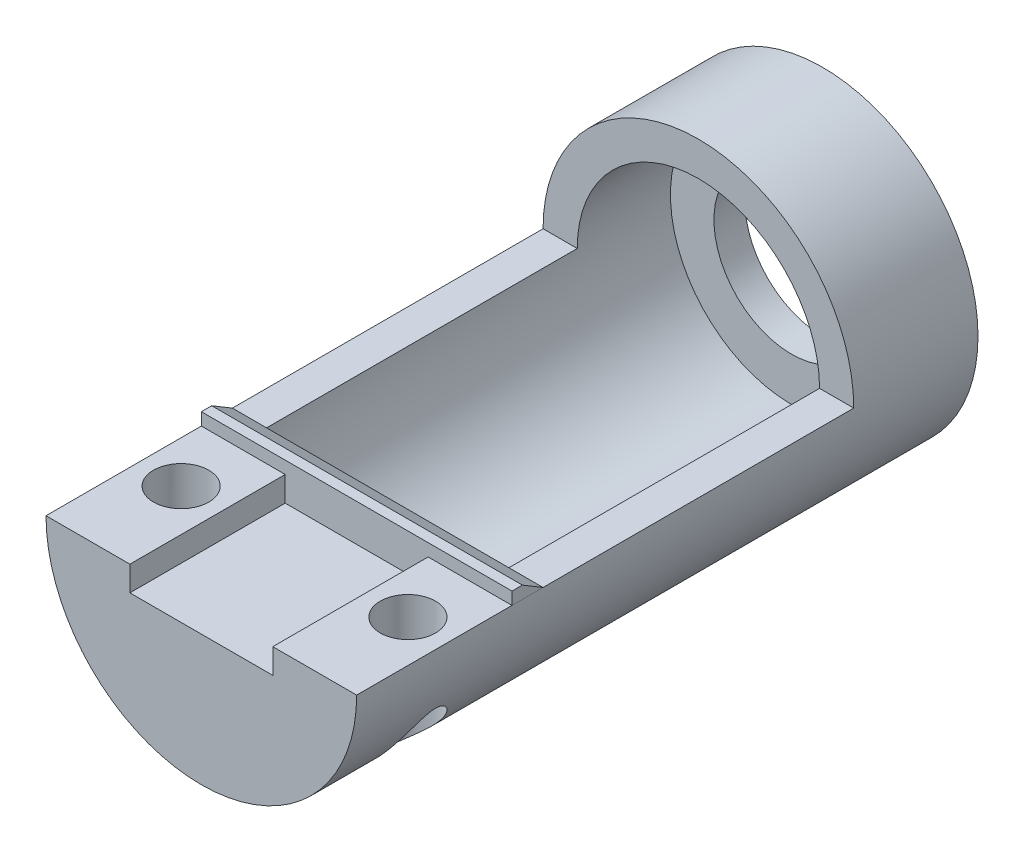
from build123d import *

# Parameters (mm, degrees)
SKETCH1_R               = 6.35
BOSS_EXTRUDE1_DEPTH     = 12.7
SKETCH3_W               = 12.7
SKETCH3_H               = 15.24
CUT_EXTRUDE2_DEPTH      = 7.35
CUT_EXTRUDE3_START      = -2.54
SKETCH4_R               = 4.953
CUT_EXTRUDE3_DEPTH      = 6.35
CUT_EXTRUDE3_DEPTH_BACK = 6.35
SKETCH5_R               = 3.175
CUT_EXTRUDE4_DEPTH      = 2.27
SKETCH7_W               = 5.842
SKETCH7_H               = 6.35
CUT_EXTRUDE5_DEPTH      = 1.016
SKETCH8_R               = 1.1303
CUT_EXTRUDE6_DEPTH      = 7.35
SKETCH10_R              = 4.953
CUT_EXTRUDE7_DEPTH      = 16.51
SKETCH11_W              = 12.869582419
SKETCH11_H              = 6.56213844
CUT_EXTRUDE8_DEPTH      = 12.7
BOSS_EXTRUDE2_DEPTH     = 6.35


with BuildPart() as part:
    # Sketch1 → Boss-Extrude1 (new body, symmetric)
    with BuildSketch(Plane.XY):
        Circle(SKETCH1_R)
    extrude(amount=BOSS_EXTRUDE1_DEPTH, both=True)

    # Sketch3 → Cut-Extrude2 (cut, through all)
    with BuildSketch(Plane(origin=(0, 0, 0), x_dir=(1, 0, 0), z_dir=(0, 1, 0))):
        with Locations((0, -5.08)):
            Rectangle(SKETCH3_W, SKETCH3_H)
    extrude(amount=CUT_EXTRUDE2_DEPTH, mode=Mode.SUBTRACT)

    # Sketch4 → Cut-Extrude3 (cut, two sides)
    with BuildSketch(Plane.XY.offset(-2.54).offset(CUT_EXTRUDE3_START)) as cut_extrude3_sk:
        Circle(SKETCH4_R)
    extrude(amount=CUT_EXTRUDE3_DEPTH, mode=Mode.SUBTRACT)
    extrude(cut_extrude3_sk.sketch, amount=-CUT_EXTRUDE3_DEPTH_BACK, mode=Mode.SUBTRACT)

    # Sketch5 → Cut-Extrude4 (cut, through all)
    with BuildSketch(Plane.XY.offset(-11.43)):
        Circle(SKETCH5_R)
    extrude(amount=-CUT_EXTRUDE4_DEPTH, mode=Mode.SUBTRACT)

    # Sketch7 → Cut-Extrude5 (cut)
    with BuildSketch(Plane(origin=(0, 0, 0), x_dir=(1, 0, 0), z_dir=(0, 1, 0))):
        with Locations((0, -9.525)):
            Rectangle(SKETCH7_W, SKETCH7_H)
    extrude(amount=-CUT_EXTRUDE5_DEPTH, mode=Mode.SUBTRACT)

    # Sketch8 → Cut-Extrude6 (cut, through all)
    with BuildSketch(Plane(origin=(0, 0, 0), x_dir=(1, 0, 0), z_dir=(0, 1, 0))):
        with Locations((-4.6355, -8.89)):
            Circle(SKETCH8_R)
        with Locations((4.6355, -8.89)):
            Circle(SKETCH8_R)
    extrude(amount=-CUT_EXTRUDE6_DEPTH, mode=Mode.SUBTRACT)

    # Sketch10 → Cut-Extrude7 (cut)
    with BuildSketch(Plane.XY.offset(-11.43)):
        Circle(SKETCH10_R)
    extrude(amount=CUT_EXTRUDE7_DEPTH, mode=Mode.SUBTRACT)

    # Sketch11 → Cut-Extrude8 (cut)
    with BuildSketch(Plane(origin=(0, 0, 5.08), x_dir=(-1, 0, 0), z_dir=(0, 0, -1))):
        with Locations((-0.08479121, 3.28106922)):
            Rectangle(SKETCH11_W, SKETCH11_H)
    extrude(amount=CUT_EXTRUDE8_DEPTH, mode=Mode.SUBTRACT)

    # Sketch12 → Boss-Extrude2 (add, symmetric)
    with BuildSketch(Plane(origin=(0, 0, 0), x_dir=(0, 0, -1), z_dir=(1, 0, 0))):
        Polygon((-6.35, 0), (-5.08, 0), (-5.9270724, 0.508), (-6.35, 0.508), align=None)
    extrude(amount=BOSS_EXTRUDE2_DEPTH, both=True)


solid = part.part
